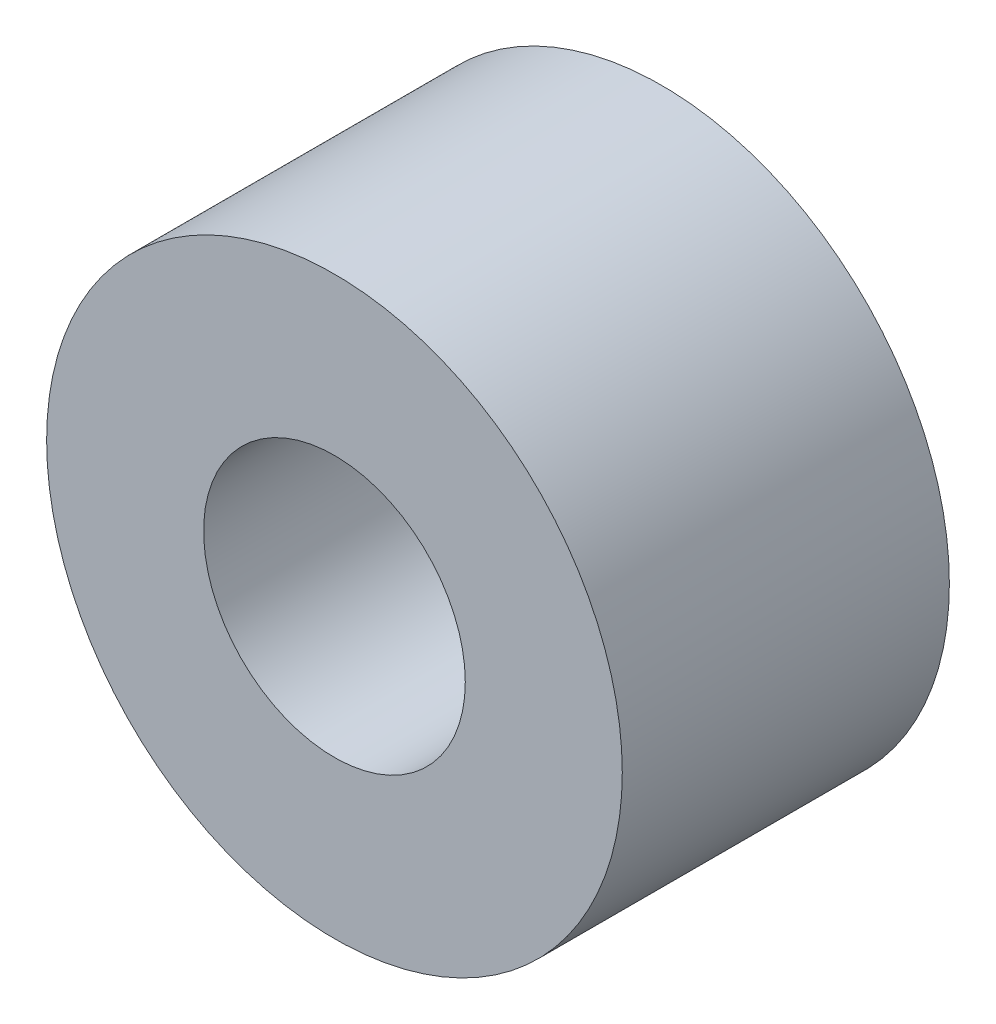
from build123d import *

# Parameters (mm, degrees)
SKETCH1_R           = 3.52
SKETCH1_R_2         = 1.6
BOSS_EXTRUDE1_DEPTH = 4


with BuildPart() as part:
    # Sketch1 → Boss-Extrude1 (new body)
    with BuildSketch(Plane.XY):
        Circle(SKETCH1_R)
        Circle(SKETCH1_R_2, mode=Mode.SUBTRACT)
    extrude(amount=BOSS_EXTRUDE1_DEPTH)


solid = part.part
